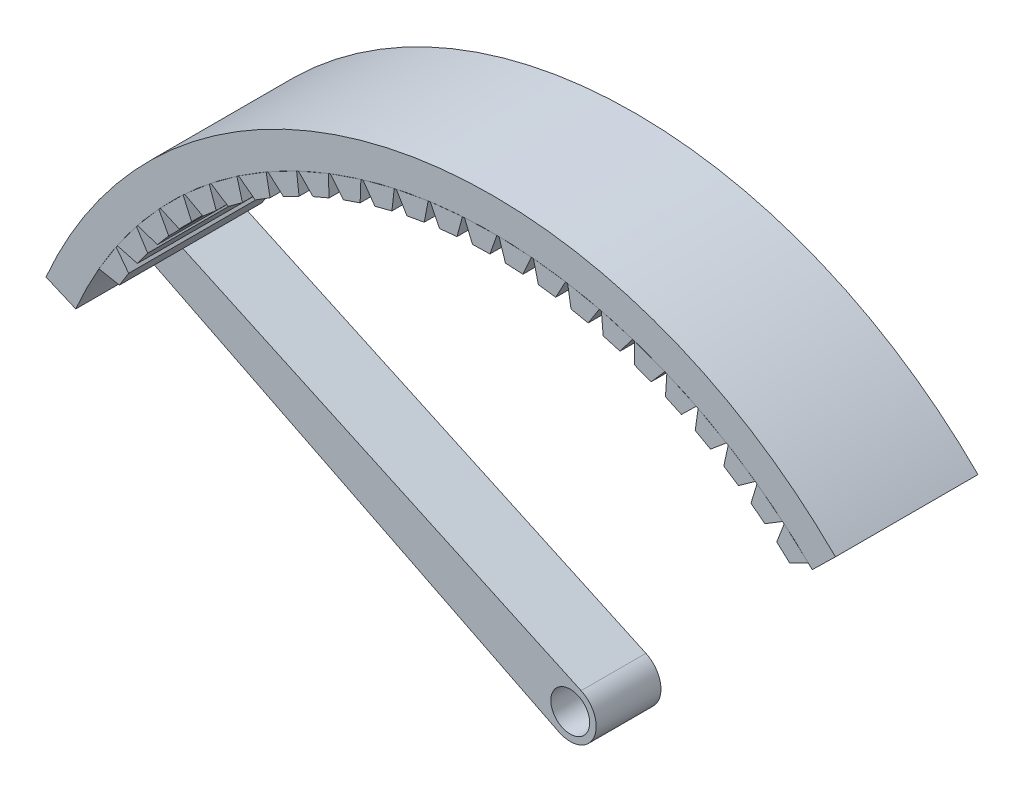
from build123d import *

# Parameters (mm, degrees)
BOSS_EXTRUDE1_DEPTH    = 5
BOSS_EXTRUDE2_DEPTH    = 11
BOSS_EXTRUDE2_2_DEPTH  = 11
BOSS_EXTRUDE2_3_DEPTH  = 11
BOSS_EXTRUDE2_4_DEPTH  = 11
BOSS_EXTRUDE2_5_DEPTH  = 11
BOSS_EXTRUDE2_6_DEPTH  = 11
BOSS_EXTRUDE2_7_DEPTH  = 11
BOSS_EXTRUDE2_8_DEPTH  = 11
BOSS_EXTRUDE2_9_DEPTH  = 11
BOSS_EXTRUDE2_10_DEPTH = 11
BOSS_EXTRUDE2_11_DEPTH = 11
BOSS_EXTRUDE2_12_DEPTH = 11
BOSS_EXTRUDE2_13_DEPTH = 11
BOSS_EXTRUDE2_14_DEPTH = 11
BOSS_EXTRUDE2_15_DEPTH = 11
BOSS_EXTRUDE2_16_DEPTH = 11
BOSS_EXTRUDE2_17_DEPTH = 11
BOSS_EXTRUDE2_18_DEPTH = 11
BOSS_EXTRUDE2_19_DEPTH = 11
BOSS_EXTRUDE2_20_DEPTH = 11
BOSS_EXTRUDE2_21_DEPTH = 11
BOSS_EXTRUDE2_22_DEPTH = 11
BOSS_EXTRUDE2_23_DEPTH = 11
BOSS_EXTRUDE2_24_DEPTH = 11
SKETCH5_R              = 1.5
BOSS_EXTRUDE8_DEPTH    = 5
BOSS_EXTRUDE9_DEPTH    = 6


with BuildPart() as part:
    # Sketch3 → Boss-Extrude1 (new body)
    with BuildSketch(Plane(origin=(0, 0, -25.970633743), x_dir=(-1, 0, 0), z_dir=(0, 0, -1))):
        with BuildLine():
            Line((21.962493028, 72.895705289), (21.962493028, 69.751585275))
            ThreePointArc((21.962493028, 69.751585275), (27.877617379, 63.662193868), (32.152641561, 56.327785096))
            Line((32.152641561, 56.327785096), (34.449258815, 57.315484031))
            ThreePointArc((34.449258815, 57.315484031), (29.261873831, 65.951924012), (21.962493028, 72.895705289))
        make_face()
        with BuildLine():
            Line((-21.962493028, 72.895705289), (-21.962493028, 69.751585275))
            ThreePointArc((-21.962493028, 69.751585275), (0, 77.5), (21.962493028, 69.751585275))
            Line((21.962493028, 69.751585275), (21.962493028, 72.895705289))
            ThreePointArc((21.962493028, 72.895705289), (0, 80), (-21.962493028, 72.895705289))
        make_face()
        with BuildLine():
            ThreePointArc((-24.674429164, 67.322823075), (-23.350061014, 68.572488386), (-21.962493028, 69.751585275))
            Line((-21.962493028, 69.751585275), (-21.962493028, 72.895705289))
            ThreePointArc((-21.962493028, 72.895705289), (-24.287766799, 71.071916), (-26.462208479, 69.07068916))
            Line((-26.462208479, 69.07068916), (-24.674429164, 67.322823075))
        make_face()
    extrude(amount=BOSS_EXTRUDE1_DEPTH)

    # Sketch5 → Boss-Extrude8 (add)
    with BuildSketch(Plane(origin=(0, 0, -25.970633743), x_dir=(-1, 0, 0), z_dir=(0, 0, -1))):
        with BuildLine():
            Line((32.152641561, 56.327785096), (0.895059482, 40.708761567))
            ThreePointArc((0.895059482, 40.708761567), (-1.8048341, 41.632682024), (-0.83937002, 44.318000156))
            Line((-0.83937002, 44.318000156), (30.896006649, 58.970212188))
            Line((30.896006649, 58.970212188), (30.993391948, 59.013023922))
            Line((30.993391948, 59.013023922), (32.238400019, 56.371276085))
            Line((32.238400019, 56.371276085), (32.152641561, 56.327785096))
        make_face()
        with Locations((0, 42.5)):
            Circle(SKETCH5_R, mode=Mode.SUBTRACT)
    extrude(amount=BOSS_EXTRUDE8_DEPTH)

    # Sketch6 → Boss-Extrude9 (add)
    with BuildSketch(Plane.XY.offset(-25.970633743)):
        with BuildLine():
            Line((24.674429164, 67.322823075), (26.462208479, 69.07068916))
            ThreePointArc((26.462208479, 69.07068916), (-7.105945059, 79.320585884), (-34.449258815, 57.315484031))
            Line((-34.449258815, 57.315484031), (-32.152641561, 56.327785096))
            ThreePointArc((-32.152641561, 56.327785096), (-31.546501322, 57.659757728), (-30.885211177, 58.965227922))
            ThreePointArc((-30.885211177, 58.965227922), (-5.206323318, 77.110608164), (24.674429164, 67.322823075))
        make_face()
    extrude(amount=BOSS_EXTRUDE9_DEPTH)


with BuildPart() as body_2:
    # Sketch4 → Boss-Extrude2 (new body)
    with BuildSketch(Plane(origin=(0, 0, -30.970633743), x_dir=(-1, 0, 0), z_dir=(0, 0, -1))):
        Polygon((-22.512842113, 69.298730194), (-24.36838523, 67.623331811), (-22.937994157, 66.893882252), (-21.932755127, 67.801528013), align=None)
    extrude(amount=-BOSS_EXTRUDE2_DEPTH)


with BuildPart() as body_3:
    # Sketch4 → Boss-Extrude2 2 (new body)
    with BuildSketch(Plane(origin=(0, 0, -30.970633743), x_dir=(-1, 0, 0), z_dir=(0, 0, -1))):
        Polygon((-19.947351518, 69.394539123), (-20.412027485, 70.931481389), (-22.389480506, 69.401880281), (-21.018635143, 68.565878922), align=None)
    extrude(amount=-BOSS_EXTRUDE2_2_DEPTH)


with BuildPart() as body_4:
    # Sketch4 → Boss-Extrude2 3 (new body)
    with BuildSketch(Plane(origin=(0, 0, -30.970633743), x_dir=(-1, 0, 0), z_dir=(0, 0, -1))):
        Polygon((-17.846671781, 70.832126174), (-18.193251357, 72.399926506), (-20.281186543, 71.024962268), (-18.977809033, 70.087240376), align=None)
    extrude(amount=-BOSS_EXTRUDE2_3_DEPTH)


with BuildPart() as body_5:
    # Sketch4 → Boss-Extrude2 4 (new body)
    with BuildSketch(Plane(origin=(0, 0, -30.970633743), x_dir=(-1, 0, 0), z_dir=(0, 0, -1))):
        Polygon((-15.642855785, 72.105981324), (-15.869336079, 73.695579373), (-18.055687213, 72.483197949), (-16.827309799, 71.449174637), align=None)
    extrude(amount=-BOSS_EXTRUDE2_4_DEPTH)


with BuildPart() as body_6:
    # Sketch4 → Boss-Extrude2 5 (new body)
    with BuildSketch(Plane(origin=(0, 0, -30.970633743), x_dir=(-1, 0, 0), z_dir=(0, 0, -1))):
        Polygon((-13.348639424, 73.208742937), (-13.453711603, 74.810952386), (-15.72584372, 73.768160152), (-14.579565218, 72.643811061), align=None)
    extrude(amount=-BOSS_EXTRUDE2_5_DEPTH)


with BuildPart() as body_7:
    # Sketch4 → Boss-Extrude2 6 (new body)
    with BuildSketch(Plane(origin=(0, 0, -30.970633743), x_dir=(-1, 0, 0), z_dir=(0, 0, -1))):
        Polygon((-10.977281019, 74.134038134), (-10.960337868, 75.739599784), (-13.305120273, 74.872423056), (-12.247565049, 73.664245821), align=None)
    extrude(amount=-BOSS_EXTRUDE2_6_DEPTH)


with BuildPart() as body_8:
    # Sketch4 → Boss-Extrude2 7 (new body)
    with BuildSketch(Plane(origin=(0, 0, -30.970633743), x_dir=(-1, 0, 0), z_dir=(0, 0, -1))):
        Polygon((-8.542484695, 74.876519616), (-8.403624131, 76.476154895), (-10.807506279, 75.789605105), (-9.844785966, 74.504581805), align=None)
    extrude(amount=-BOSS_EXTRUDE2_7_DEPTH)


with BuildPart() as body_9:
    # Sketch4 → Boss-Extrude2 8 (new body)
    with BuildSketch(Plane(origin=(0, 0, -30.970633743), x_dir=(-1, 0, 0), z_dir=(0, 0, -1))):
        Polygon((-6.058321189, 75.431896569), (-5.798345687, 77.016361154), (-8.2474355, 76.514405885), (-7.385113675, 75.159962695), align=None)
    extrude(amount=-BOSS_EXTRUDE2_8_DEPTH)


with BuildPart() as body_10:
    # Sketch4 → Boss-Extrude2 9 (new body)
    with BuildSketch(Plane(origin=(0, 0, -30.970633743), x_dir=(-1, 0, 0), z_dir=(0, 0, -1))):
        Polygon((-3.539146527, 75.796959457), (-3.159558493, 77.357096697), (-5.639702631, 77.042636759), (-4.882762671, 75.626601032), align=None)
    extrude(amount=-BOSS_EXTRUDE2_9_DEPTH)


with BuildPart() as body_11:
    # Sketch4 → Boss-Extrude2 10 (new body)
    with BuildSketch(Plane(origin=(0, 0, -30.970633743), x_dir=(-1, 0, 0), z_dir=(0, 0, -1))):
        Polygon((-0.99951907, 75.969598576), (-0.502512149, 77.496392408), (-2.999377813, 77.37124507), (-2.352194087, 75.901800104), align=None)
    extrude(amount=-BOSS_EXTRUDE2_10_DEPTH)


with BuildPart() as body_12:
    # Sketch4 → Boss-Extrude2 11 (new body)
    with BuildSketch(Plane(origin=(0, 0, -30.970633743), x_dir=(-1, 0, 0), z_dir=(0, 0, -1))):
        Polygon((1.545884627, 75.948816241), (2.157438222, 77.433443293), (-0.341719532, 77.498331785), (0.191967872, 75.983969531), align=None)
    extrude(amount=-BOSS_EXTRUDE2_11_DEPTH)


with BuildPart() as body_13:
    # Sketch4 → Boss-Extrude2 12 (new body)
    with BuildSketch(Plane(origin=(0, 0, -30.970633743), x_dir=(-1, 0, 0), z_dir=(0, 0, -1))):
        Polygon((4.082354628, 75.734732554), (4.804920717, 77.168613138), (2.317913552, 77.423162468), (2.735020445, 75.872634454), align=None)
    extrude(amount=-BOSS_EXTRUDE2_12_DEPTH)


with BuildPart() as body_14:
    # Sketch4 → Boss-Extrude2 13 (new body)
    with BuildSketch(Plane(origin=(0, 0, -30.970633743), x_dir=(-1, 0, 0), z_dir=(0, 0, -1))):
        Polygon((6.595232622, 75.328584708), (7.424635482, 76.7034324), (4.964151369, 77.146171523), (5.262267282, 75.56843828), align=None)
    extrude(amount=-BOSS_EXTRUDE2_13_DEPTH)


with BuildPart() as body_15:
    # Sketch4 → Boss-Extrude2 14 (new body)
    with BuildSketch(Plane(origin=(0, 0, -30.970633743), x_dir=(-1, 0, 0), z_dir=(0, 0, -1))):
        Polygon((9.06999664, 74.732719839), (10.001443135, 76.040589369), (7.58170126, 76.668959686), (7.759103375, 75.073138965), align=None)
    extrude(amount=-BOSS_EXTRUDE2_14_DEPTH)


with BuildPart() as body_16:
    # Sketch4 → Boss-Extrude2 15 (new body)
    with BuildSketch(Plane(origin=(0, 0, -30.970633743), x_dir=(-1, 0, 0), z_dir=(0, 0, -1))):
        Polygon((11.492344973, 73.950581461), (12.520452257, 75.183914626), (10.155436353, 75.994284773), (10.21109946, 74.389598854), align=None)
    extrude(amount=-BOSS_EXTRUDE2_15_DEPTH)


with BuildPart() as body_17:
    # Sketch4 → Boss-Extrude2 16 (new body)
    with BuildSketch(Plane(origin=(0, 0, -30.970633743), x_dir=(-1, 0, 0), z_dir=(0, 0, -1))):
        Polygon((13.848278823, 72.986689569), (14.967105444, 74.138358912), (12.670482985, 75.126045745), (12.604085406, 73.521768137), align=None)
    extrude(amount=-BOSS_EXTRUDE2_16_DEPTH)


with BuildPart() as body_18:
    # Sketch4 → Boss-Extrude2 17 (new body)
    with BuildSketch(Plane(origin=(0, 0, -30.970633743), x_dir=(-1, 0, 0), z_dir=(0, 0, -1))):
        Polygon((16.124183204, 71.846614511), (17.32726344, 72.909964513), (15.112306651, 74.06926017), (14.924232099, 72.474662025), align=None)
    extrude(amount=-BOSS_EXTRUDE2_17_DEPTH)


with BuildPart() as body_19:
    # Sketch4 → Boss-Extrude2 18 (new body)
    with BuildSketch(Plane(origin=(0, 0, -30.970633743), x_dir=(-1, 0, 0), z_dir=(0, 0, -1))):
        Polygon((18.306905619, 70.536944803), (19.587286848, 71.505830344), (17.466796006, 72.830035234), (17.158131367, 71.254331764), align=None)
    extrude(amount=-BOSS_EXTRUDE2_18_DEPTH)


with BuildPart() as body_20:
    # Sketch4 → Boss-Extrude2 19 (new body)
    with BuildSketch(Plane(origin=(0, 0, -30.970633743), x_dir=(-1, 0, 0), z_dir=(0, 0, -1))):
        Polygon((20.383832075, 69.065249052), (21.734114948, 69.934070923), (19.720344412, 71.41553244), (19.292873465, 69.867829667), align=None)
    extrude(amount=-BOSS_EXTRUDE2_19_DEPTH)


with BuildPart() as body_21:
    # Sketch4 → Boss-Extrude2 20 (new body)
    with BuildSketch(Plane(origin=(0, 0, -30.970633743), x_dir=(-1, 0, 0), z_dir=(0, 0, -1))):
        Polygon((22.342959973, 67.440032215), (23.75534118, 68.203769479), (21.859928567, 69.833926228), (21.316121675, 68.323168356), align=None)
    extrude(amount=-BOSS_EXTRUDE2_20_DEPTH)


with BuildPart() as body_22:
    # Sketch4 → Boss-Extrude2 21 (new body)
    with BuildSketch(Plane(origin=(0, 0, -30.970633743), x_dir=(-1, 0, 0), z_dir=(0, 0, -1))):
        Polygon((24.172967476, 65.670686452), (25.639284838, 66.324925456), (23.873183775, 68.09435673), (23.216183609, 66.629274458), align=None)
    extrude(amount=-BOSS_EXTRUDE2_21_DEPTH)


with BuildPart() as body_23:
    # Sketch4 → Boss-Extrude2 22 (new body)
    with BuildSketch(Plane(origin=(0, 0, -30.970633743), x_dir=(-1, 0, 0), z_dir=(0, 0, -1))):
        Polygon((25.863278934, 63.767436846), (27.375058576, 64.308396731), (25.748475395, 66.206876953), (24.98207877, 64.795937019), align=None)
    extrude(amount=-BOSS_EXTRUDE2_22_DEPTH)


with BuildPart() as body_24:
    # Sketch4 → Boss-Extrude2 23 (new body)
    with BuildSketch(Plane(origin=(0, 0, -30.970633743), x_dir=(-1, 0, 0), z_dir=(0, 0, -1))):
        Polygon((27.404126006, 61.741282314), (28.952631324, 62.165836861), (27.474966079, 64.182394677), (26.603602018, 62.833750931), align=None)
    extrude(amount=-BOSS_EXTRUDE2_23_DEPTH)


with BuildPart() as body_25:
    # Sketch4 → Boss-Extrude2 24 (new body)
    with BuildSketch(Plane(origin=(0, 0, -30.970633743), x_dir=(-1, 0, 0), z_dir=(0, 0, -1))):
        Polygon((28.786604106, 59.603932041), (30.362886258, 59.909627742), (29.042678407, 62.032609426), (28.071382537, 60.754055705), align=None)
    extrude(amount=-BOSS_EXTRUDE2_24_DEPTH)


solid = Compound([part.part, body_2.part, body_3.part, body_4.part, body_5.part, body_6.part, body_7.part, body_8.part, body_9.part, body_10.part, body_11.part, body_12.part, body_13.part, body_14.part, body_15.part, body_16.part, body_17.part, body_18.part, body_19.part, body_20.part, body_21.part, body_22.part, body_23.part, body_24.part, body_25.part])
